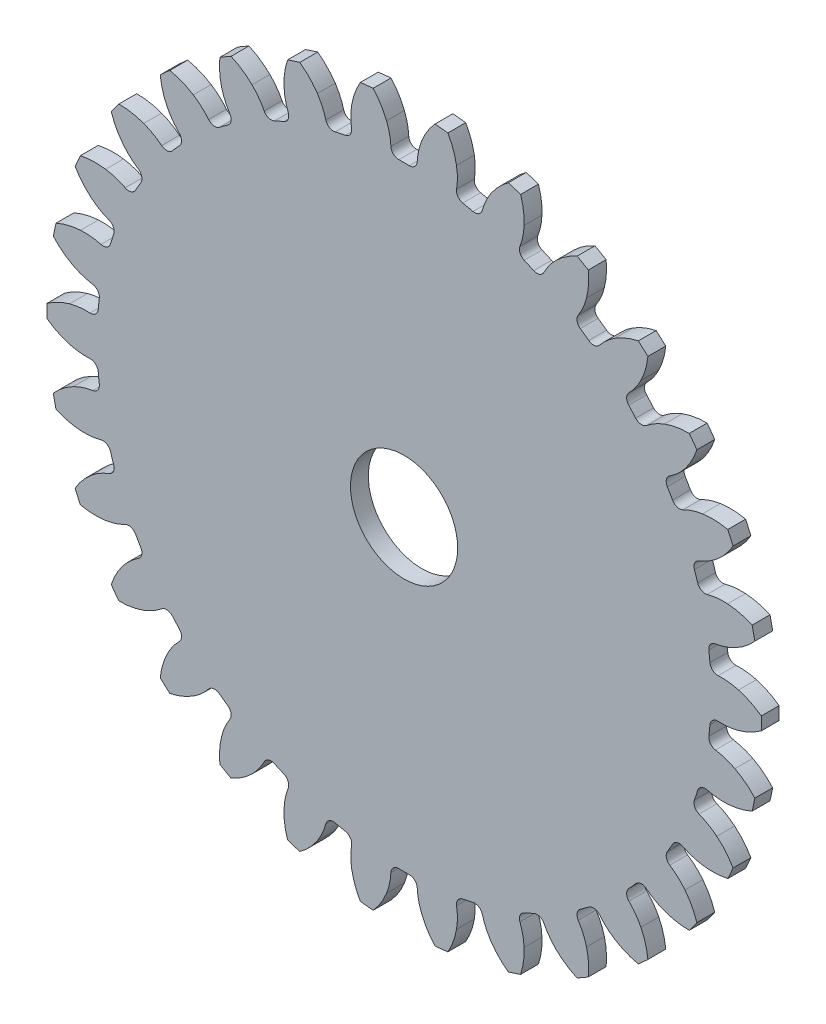
from build123d import *

# Parameters (mm, degrees)
SKETCH1_R               = 50.8
GEAR_BASE_DEPTH         = 1.27
GEAR_CUT_DEPTH          = 72.886936226
GEAR_TEETH_COUNT        = 30
SKETCH3_R               = 4.7625
BORE_DEPTH              = 72.752368529
CUT_EXTRUDE3_DEPTH      = 72.752368529
CUT_EXTRUDE3_DEPTH_BACK = 72.752368529
SKETCH5_R               = 7.62


with BuildPart() as part:
    # Sketch1 → GEAR_BASE (new, symmetric)
    with BuildSketch(Plane.XY):
        Circle(SKETCH1_R)
    extrude(amount=GEAR_BASE_DEPTH, both=True)

    # Sketch2 → GEAR_CUT (cut, through all)
    with BuildSketch(Plane.XY.offset(1.27)):
        with BuildLine():
            ThreePointArc((-49.872591357, -9.662537522), (-50.521712285, -5.310045934), (-50.791710092, -0.917706901))
            ThreePointArc((-50.791710092, -0.917706901), (-49.247291805, -1.852666983), (-47.559654919, -2.4939625))
            ThreePointArc((-47.559654919, -2.4939625), (-46.120309896, -2.772253488), (-44.654879163, -2.813152568))
            ThreePointArc((-44.654879163, -2.813152568), (-43.86698879, -3.08349419), (-43.488323172, -3.825429621))
            ThreePointArc((-43.488323172, -3.825429621), (-43.417096495, -4.563320725), (-43.333350511, -5.299895996))
            ThreePointArc((-43.333350511, -5.299895996), (-43.549484327, -6.104347366), (-44.263950221, -6.532592995))
            ThreePointArc((-44.263950221, -6.532592995), (-45.68885438, -6.877278514), (-47.038886311, -7.448744833))
            ThreePointArc((-47.038886311, -7.448744833), (-48.556311447, -8.426905943), (-49.872591357, -9.662537522))
        make_face()
    gear_cut = extrude(amount=-GEAR_CUT_DEPTH, mode=Mode.SUBTRACT)

    # GEAR_TEETH: GEAR_CUT ×30 about axis
    gear_teeth_axis = Axis((0, 0, -3.2131), (0, 0, 1))
    for i in range(1, GEAR_TEETH_COUNT):
        add(gear_cut.rotate(gear_teeth_axis, i * 360 / GEAR_TEETH_COUNT), mode=Mode.SUBTRACT)

    # Sketch3 → BORE (cut, through all)
    with BuildSketch(Plane.XY.offset(1.27)):
        Circle(SKETCH3_R)
    extrude(amount=-BORE_DEPTH, mode=Mode.SUBTRACT)

    # Sketch5 → Cut-Extrude3 (cut, two sides: drawn at the far end of the back side and taken through both)
    with BuildSketch(Plane.XY.offset(1.27).offset(-CUT_EXTRUDE3_DEPTH_BACK)):
        Circle(SKETCH5_R)
    extrude(amount=CUT_EXTRUDE3_DEPTH + CUT_EXTRUDE3_DEPTH_BACK, mode=Mode.SUBTRACT)


solid = part.part
